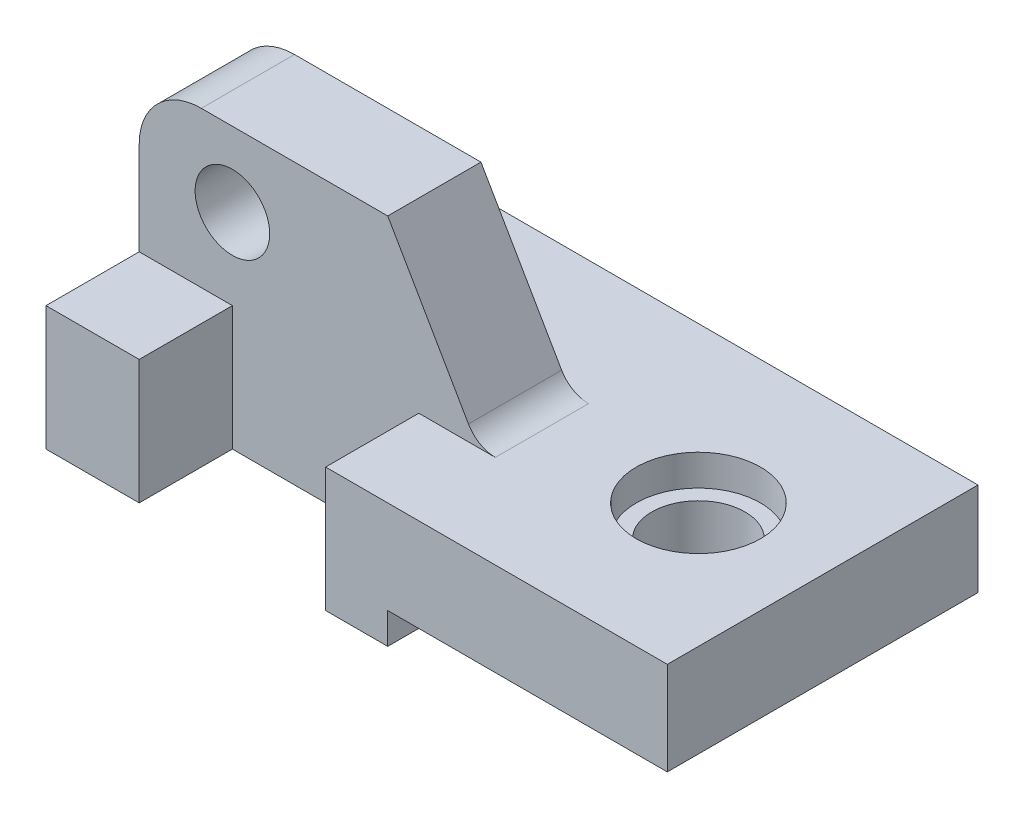
from build123d import *

# Parameters (mm, degrees)
SKETCH2_W             = 15
SKETCH2_H             = 20
BOSS_EXTRUDE1_DEPTH   = 15
BOSS_EXTRUDE1_2_DEPTH = 15
BOSS_EXTRUDE2_DEPTH   = 35
SKETCH9_R             = 6
BOSS_EXTRUDE6_DEPTH   = 15
HOLE1_D               = 15
HOLE1_DEPTH           = 99.968745116
HOLE1_CBORE_D         = 20
HOLE1_CBORE_DEPTH     = 5


with BuildPart() as part:
    # Sketch2 → Boss-Extrude1 (new body)
    with BuildSketch(Plane.XY):
        with Locations((7.5, 10)):
            Rectangle(SKETCH2_W, SKETCH2_H)
    extrude(amount=BOSS_EXTRUDE1_DEPTH)



with BuildPart() as body_2:
    # Sketch2 → Boss-Extrude1 2 (new body)
    with BuildSketch(Plane.XY):
        Polygon((45, 20), (45, 0), (55, 0), (55, 5), (100, 5), (100, 20), align=None)
    extrude(amount=BOSS_EXTRUDE1_2_DEPTH)


with BuildPart() as part_1:
    add(part.part)

    add(body_2.part)  # Boss-Extrude2 merges body 2
    # Sketch3 → Boss-Extrude2 (add)
    with BuildSketch(Plane.XY):
        Polygon((100, 20), (100, 5), (55, 5), (55, 0), (0, 0), (0, 20), align=None)
    extrude(amount=-BOSS_EXTRUDE2_DEPTH)

    # Sketch9 → Boss-Extrude6 (add)
    with BuildSketch(Plane.XY):
        with BuildLine():
            Line((40, 45), (10, 45))
            ThreePointArc((10, 45), (2.928932188, 42.071067812), (0, 35))
            Line((0, 35), (0, 20))
            Line((0, 20), (57.320508076, 20))
            ThreePointArc((57.320508076, 20), (54.820508076, 20.669872981), (52.990381057, 22.5))
            Line((52.990381057, 22.5), (40, 45))
        make_face()
        with Locations((15, 33)):
            Circle(SKETCH9_R, mode=Mode.SUBTRACT)
    extrude(amount=-BOSS_EXTRUDE6_DEPTH)

    # Hole1
    with Locations(Plane(origin=(0, 20, 0), x_dir=(1, 0, 0), z_dir=(0, 1, 0))):
        with Locations((80, 10)):
            CounterBoreHole(HOLE1_D / 2, HOLE1_CBORE_D / 2, HOLE1_CBORE_DEPTH, depth=HOLE1_DEPTH)


solid = part_1.part
